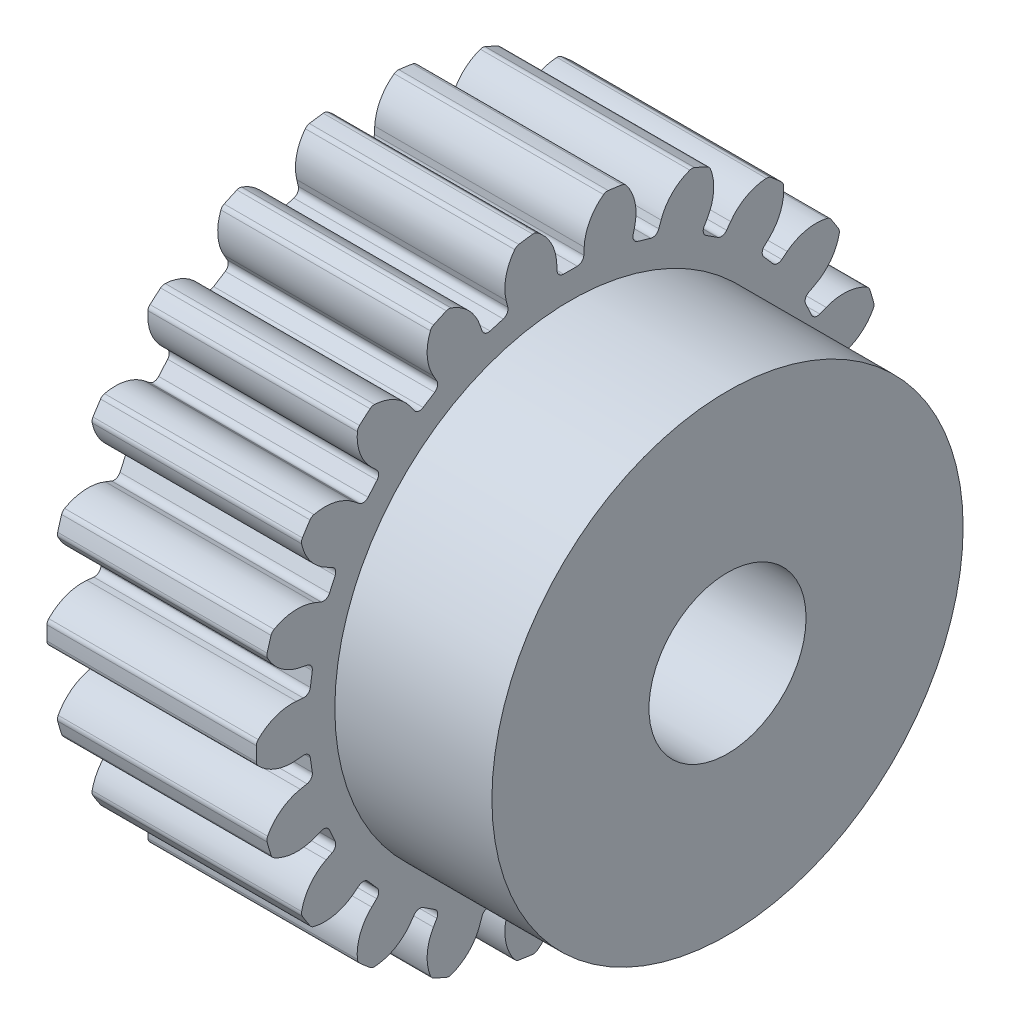
from build123d import *

# Parameters (mm, degrees)
ESQUISSE1_R                        = 12
ESQUISSE1_R_2                      = 3
EXTRUSION1_DEPTH                   = 8
ENL_V_MAT_EXTRU_2_DEPTH            = 8
CONG_2_R                           = 0.25
R_P_TITION_CIRCULAIRE1_COUNT       = 22
CONG_2_OF_R_P_TITION_CIRCULAIRE1_R = 0.25
ESQUISSE23_R                       = 9
ESQUISSE23_R_2                     = 3
EXTRUSION2_DEPTH                   = 6


with BuildPart() as part:
    # Esquisse1 → Extrusion1 (new body)
    with BuildSketch(Plane(origin=(0, 0, 0), x_dir=(0, 0, -1), z_dir=(1, 0, 0))):
        Circle(ESQUISSE1_R)
        Circle(ESQUISSE1_R_2, mode=Mode.SUBTRACT)
    extrude(amount=EXTRUSION1_DEPTH)

    # Esquisse22 → Enlèv. mat.-Extru.2 (cut)
    with BuildSketch(Plane.ZY):
        with BuildLine():
            Line((-0.5, 10), (0.5, 10))
            Line((0.5, 10), (0.525, 10.5))
            ThreePointArc((0.525, 10.5), (0.764868359, 11.31166675), (1.349251403, 11.923905428))
            ThreePointArc((1.349251403, 11.923905428), (0, 12), (-1.349251403, 11.923905428))
            ThreePointArc((-1.349251403, 11.923905428), (-0.764868359, 11.31166675), (-0.525, 10.5))
            Line((-0.525, 10.5), (-0.5, 10))
        make_face()
    enl_v_mat_extru_2 = extrude(amount=-ENL_V_MAT_EXTRU_2_DEPTH, mode=Mode.SUBTRACT)

    # Congé2
    cong_2_edges = [part.edges().sort_by_distance(p)[0] for p in [
        (4, 10, -0.5),
        (4, 11.923905428, -1.349251403),
        (4, 11.923905428, 1.349251403),
        (4, 10, 0.5),
    ]]
    fillet(cong_2_edges, radius=CONG_2_R)

    # Répétition circulaire1: Enlèv. mat.-Extru.2 ×22 about axis
    r_p_tition_circulaire1_axis = Axis((0, 0, 0), (1, 0, 0))
    for i in range(1, R_P_TITION_CIRCULAIRE1_COUNT):
        add(enl_v_mat_extru_2.rotate(r_p_tition_circulaire1_axis, i * 360 / R_P_TITION_CIRCULAIRE1_COUNT), mode=Mode.SUBTRACT)

    # Congé2 of Répétition circulaire1
    cong_2_of_r_p_tition_circulaire1_edges = [part.edges().sort_by_distance(p)[0] for p in [
        (4, 9.735796015, 2.337579082),
        (4, 11.821031524, 2.064755123),
        (4, 11.060775428, 4.653949605),
        (4, 9.454063458, 3.297072055),
        (4, 8.682855737, 4.985781408),
        (4, 10.760487948, 5.311487468),
        (4, 9.301567185, 7.581612487),
        (4, 8.14221492, 5.827034941),
        (4, 6.926482127, 7.230065377),
        (4, 8.828193634, 8.127914687),
        (4, 6.788801286, 9.895058216),
        (4, 6.170732552, 7.884926111),
        (4, 4.608966128, 8.888612447),
        (4, 6.180691575, 10.285866597),
        (4, 3.726047082, 11.406865176),
        (4, 3.699334132, 9.30402746),
        (4, 1.918059104, 9.827057),
        (4, 3.032466642, 11.610518768),
        (4, 0.361430703, 11.994555759),
        (4, 0.928237662, 9.969371838),
        (4, -0.928237662, 9.969371838),
        (4, -0.361430703, 11.994555759),
        (4, -3.032466642, 11.610518768),
        (4, -1.918059104, 9.827057),
        (4, -3.699334132, 9.30402746),
        (4, -3.726047082, 11.406865176),
        (4, -6.180691575, 10.285866597),
        (4, -4.608966128, 8.888612447),
        (4, -6.170732552, 7.884926111),
        (4, -6.788801286, 9.895058216),
        (4, -8.828193634, 8.127914687),
        (4, -6.926482127, 7.230065377),
        (4, -8.14221492, 5.827034941),
        (4, -9.301567185, 7.581612487),
        (4, -10.760487948, 5.311487468),
        (4, -8.682855737, 4.985781408),
        (4, -9.454063458, 3.297072055),
        (4, -11.060775428, 4.653949605),
        (4, -11.821031524, 2.064755123),
        (4, -9.735796015, 2.337579082),
        (4, -10, 0.5),
        (4, -11.923905428, 1.349251403),
        (4, -11.923905428, -1.349251403),
        (4, -10, -0.5),
        (4, -9.735796015, -2.337579082),
        (4, -11.821031524, -2.064755123),
        (4, -11.060775428, -4.653949605),
        (4, -9.454063458, -3.297072055),
        (4, -8.682855737, -4.985781408),
        (4, -10.760487948, -5.311487468),
        (4, -9.301567185, -7.581612487),
        (4, -8.14221492, -5.827034941),
        (4, -6.926482127, -7.230065377),
        (4, -8.828193634, -8.127914687),
        (4, -6.788801286, -9.895058216),
        (4, -6.170732552, -7.884926111),
        (4, -4.608966128, -8.888612447),
        (4, -6.180691575, -10.285866597),
        (4, -3.726047082, -11.406865176),
        (4, -3.699334132, -9.30402746),
        (4, -1.918059104, -9.827057),
        (4, -3.032466642, -11.610518768),
        (4, -0.361430703, -11.994555759),
        (4, -0.928237662, -9.969371838),
        (4, 0.928237662, -9.969371838),
        (4, 0.361430703, -11.994555759),
        (4, 3.032466642, -11.610518768),
        (4, 1.918059104, -9.827057),
        (4, 3.699334132, -9.30402746),
        (4, 3.726047082, -11.406865176),
        (4, 6.180691575, -10.285866597),
        (4, 4.608966128, -8.888612447),
        (4, 6.170732552, -7.884926111),
        (4, 6.788801286, -9.895058216),
        (4, 8.828193634, -8.127914687),
        (4, 6.926482127, -7.230065377),
        (4, 8.14221492, -5.827034941),
        (4, 9.301567185, -7.581612487),
        (4, 10.760487948, -5.311487468),
        (4, 8.682855737, -4.985781408),
        (4, 9.454063458, -3.297072055),
        (4, 11.060775428, -4.653949605),
        (4, 11.821031524, -2.064755123),
        (4, 9.735796015, -2.337579082),
    ]]
    fillet(cong_2_of_r_p_tition_circulaire1_edges, radius=CONG_2_OF_R_P_TITION_CIRCULAIRE1_R)

    # Esquisse23 → Extrusion2 (add)
    with BuildSketch(Plane(origin=(8, 0, 0), x_dir=(0, 0, -1), z_dir=(1, 0, 0))):
        Circle(ESQUISSE23_R)
        Circle(ESQUISSE23_R_2, mode=Mode.SUBTRACT)
    extrude(amount=EXTRUSION2_DEPTH)


solid = part.part
